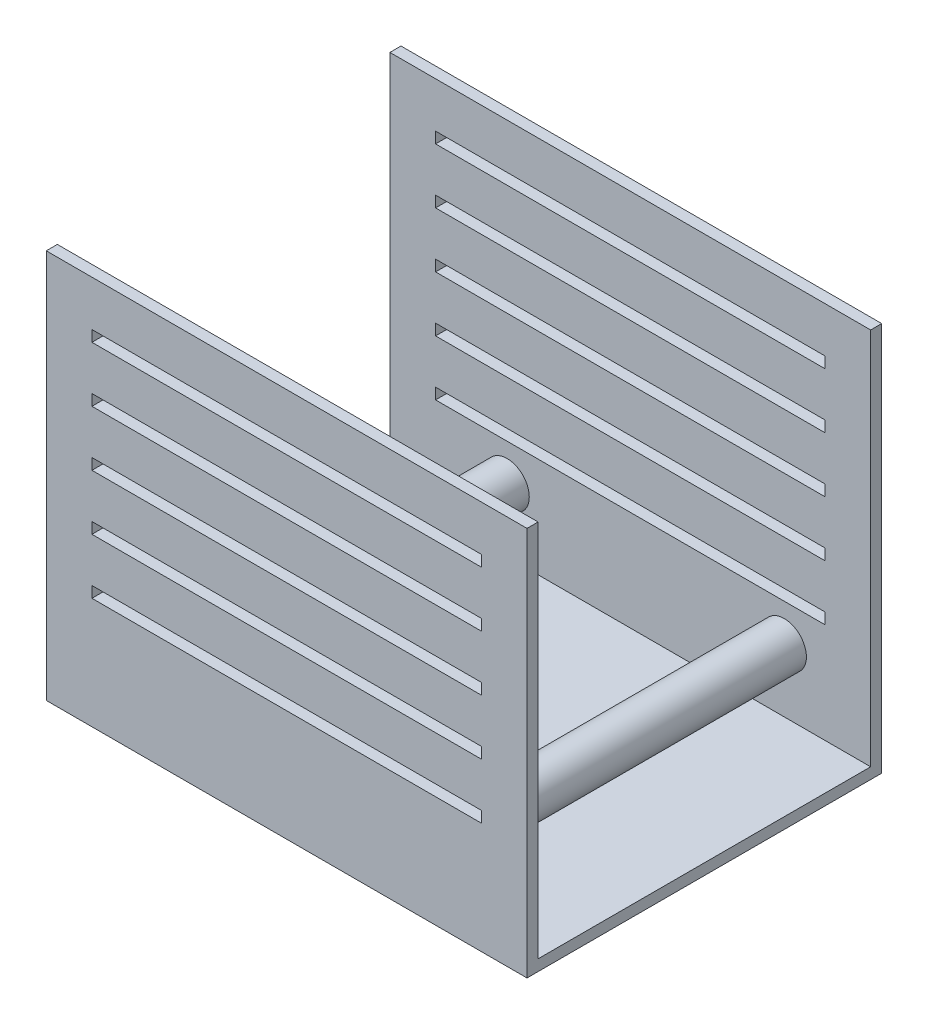
from build123d import *

# Parameters (mm, degrees)
SKETCH1_R               = 4
BOSS_EXTRUDE1_DEPTH     = 30
BOSS_EXTRUDE1_2_DEPTH   = 30
SKETCH2_W               = 86.738485283
SKETCH2_H               = 68.254231625
BOSS_EXTRUDE2_DEPTH     = 2
SKETCH4_W               = 70.255349131
SKETCH4_H               = 2
CUT_EXTRUDE_THIN1_DEPTH = 2
SKETCH3_W               = 86.738485283
SKETCH3_H               = 64
BOSS_EXTRUDE3_DEPTH     = 2


with BuildPart() as part:
    # Sketch1 → Boss-Extrude1 (new body, symmetric)
    with BuildSketch(Plane.XY):
        with Locations((-25, -30.44)):
            Circle(SKETCH1_R)
    extrude(amount=BOSS_EXTRUDE1_DEPTH, both=True)



with BuildPart() as body_2:
    # Sketch1 → Boss-Extrude1 2 (new body, symmetric)
    with BuildSketch(Plane.XY):
        with Locations((25, -30.44)):
            Circle(SKETCH1_R)
    extrude(amount=BOSS_EXTRUDE1_2_DEPTH, both=True)


with BuildPart() as part_1:
    add(part.part)

    add(body_2.part)  # Boss-Extrude2 merges body 2
    # Sketch2 → Boss-Extrude2 (add)
    with BuildSketch(Plane.XY.offset(30)):
        with Locations((-2.776823357, -7.681992187)):
            Rectangle(SKETCH2_W, SKETCH2_H)
    boss_extrude2 = extrude(amount=BOSS_EXTRUDE2_DEPTH)

    # Sketch4 → Cut-Extrude-Thin1 (cut)
    with BuildSketch(Plane.XY.offset(32)):
        with Locations((-2.776823357, 17.267458724)):
            Rectangle(SKETCH4_W, SKETCH4_H)
        with Locations((-2.776823357, 7.267458724)):
            Rectangle(SKETCH4_W, SKETCH4_H)
        with Locations((-2.776823357, -2.732541276)):
            Rectangle(SKETCH4_W, SKETCH4_H)
        with Locations((-2.776823357, -12.732541276)):
            Rectangle(SKETCH4_W, SKETCH4_H)
        with Locations((-2.776823357, -22.732541276)):
            Rectangle(SKETCH4_W, SKETCH4_H)
    cut_extrude_thin1 = extrude(amount=-CUT_EXTRUDE_THIN1_DEPTH, mode=Mode.SUBTRACT)

    # Mirror1: Boss-Extrude2, Cut-Extrude-Thin1 across plane
    add(boss_extrude2.mirror(Plane.XY))
    add(cut_extrude_thin1.mirror(Plane.XY), mode=Mode.SUBTRACT)

    # Sketch3 → Boss-Extrude3 (add)
    with BuildSketch(Plane.XZ.offset(41.809107999)):
        with Locations((-2.776823357, 0)):
            Rectangle(SKETCH3_W, SKETCH3_H)
    extrude(amount=BOSS_EXTRUDE3_DEPTH)


solid = part_1.part
